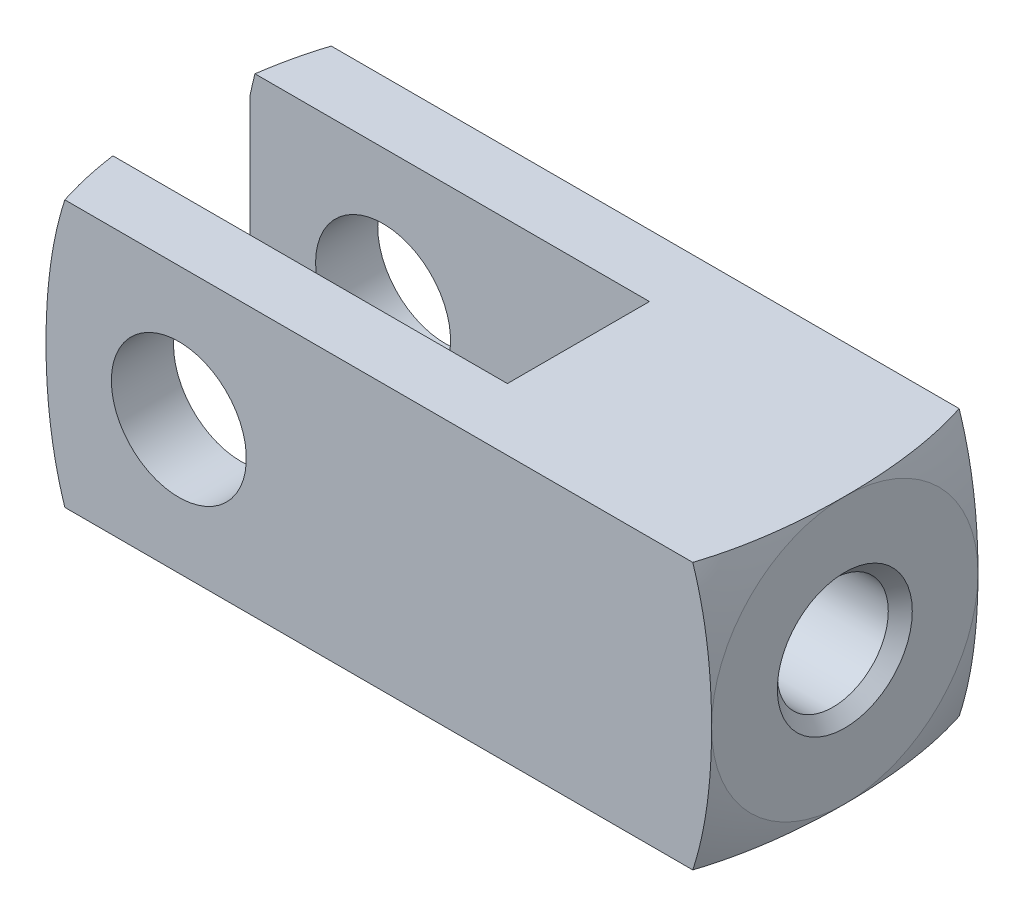
from build123d import *

# Parameters (mm, degrees)
BOSS_EXTRUDE1_DEPTH      = 4.7625
BOSS_EXTRUDE1_DEPTH_BACK = 4.7625
SKETCH1_W                = 23.7998
SKETCH1_H                = 9.525
CUT_EXTRUDE1_DEPTH       = 4.7625
CUT_EXTRUDE1_DEPTH_BACK  = 4.7625
SKETCH2_W                = 14.2748
SKETCH2_H                = 5.08
HOLE1_D                  = 3.96748
HOLE1_DEPTH              = 7.874
HOLE1_CSINK_D            = 4.826
HOLE1_CSINK_ANGLE        = 90
HOLE2_D                  = 3.96748
HOLE3_D                  = 4.826


with BuildPart() as part:
    # Sketch1 → Boss-Extrude1 (new, two sides: drawn at the far end of the back side and taken through both)
    with BuildSketch(Plane.XY.offset(-BOSS_EXTRUDE1_DEPTH_BACK)):
        with Locations((7.1501, 0)):
            Rectangle(SKETCH1_W, SKETCH1_H)
    extrude(amount=BOSS_EXTRUDE1_DEPTH + BOSS_EXTRUDE1_DEPTH_BACK)

    # Sketch2 → Cut-Extrude1 (cut, two sides: drawn at the far end of the back side and taken through both)
    with BuildSketch(Plane(origin=(0, 0, 0), x_dir=(1, 0, 0), z_dir=(0, 1, 0)).offset(-CUT_EXTRUDE1_DEPTH_BACK)):
        with Locations((2.3876, 0)):
            Rectangle(SKETCH2_W, SKETCH2_H)
    extrude(amount=CUT_EXTRUDE1_DEPTH + CUT_EXTRUDE1_DEPTH_BACK, mode=Mode.SUBTRACT)

    # Hole1
    with Locations(Plane(origin=(19.05, 0, 0), x_dir=(0, 0, -1), z_dir=(1, 0, 0))):
        with Locations((0, 0)):
            CounterSinkHole(HOLE1_D / 2, HOLE1_CSINK_D / 2, depth=HOLE1_DEPTH, counter_sink_angle=HOLE1_CSINK_ANGLE)

    # Hole2 (through all)
    with Locations(Plane(origin=(11.176, 0, 0), x_dir=(0, 0, -1), z_dir=(1, 0, 0))):
        with Locations((0, 0)):
            Hole(HOLE2_D / 2)

    # Hole3 (through all)
    with Locations(Plane(origin=(0, 0, -4.7625), x_dir=(-1, 0, 0), z_dir=(0, 0, -1))):
        with Locations((0, 0)):
            Hole(HOLE3_D / 2)

    # Sketch9 → Cut-Revolve1 (revolve, cut)
    with BuildSketch(Plane.XY):
        with BuildLine():
            Line((19.05, 0), (19.05, 4.7625))
            ThreePointArc((19.05, 4.7625), (18.092047749, 7.310175466), (16.51, 9.525))
            Line((16.51, 9.525), (23.8125, 9.525))
            Line((23.8125, 9.525), (23.8125, 0))
            Line((23.8125, 0), (19.05, 0))
        make_face()
    revolve(axis=Axis((23.8125, 0, 0), (-1, 0, 0)), mode=Mode.SUBTRACT)

    # Sketch10 → Cut-Revolve2 (revolve, cut)
    with BuildSketch(Plane.XY):
        with BuildLine():
            Line((-9.5123, 0), (-9.5123, 9.525))
            Line((-9.5123, 9.525), (-2.2098, 9.525))
            ThreePointArc((-2.2098, 9.525), (-3.791847749, 7.310175466), (-4.7498, 4.7625))
            Line((-4.7498, 4.7625), (-4.7498, 0))
            Line((-4.7498, 0), (-9.5123, 0))
        make_face()
    revolve(axis=Axis((-4.7498, 0, 0), (-1, 0, 0)), mode=Mode.SUBTRACT)


solid = part.part
